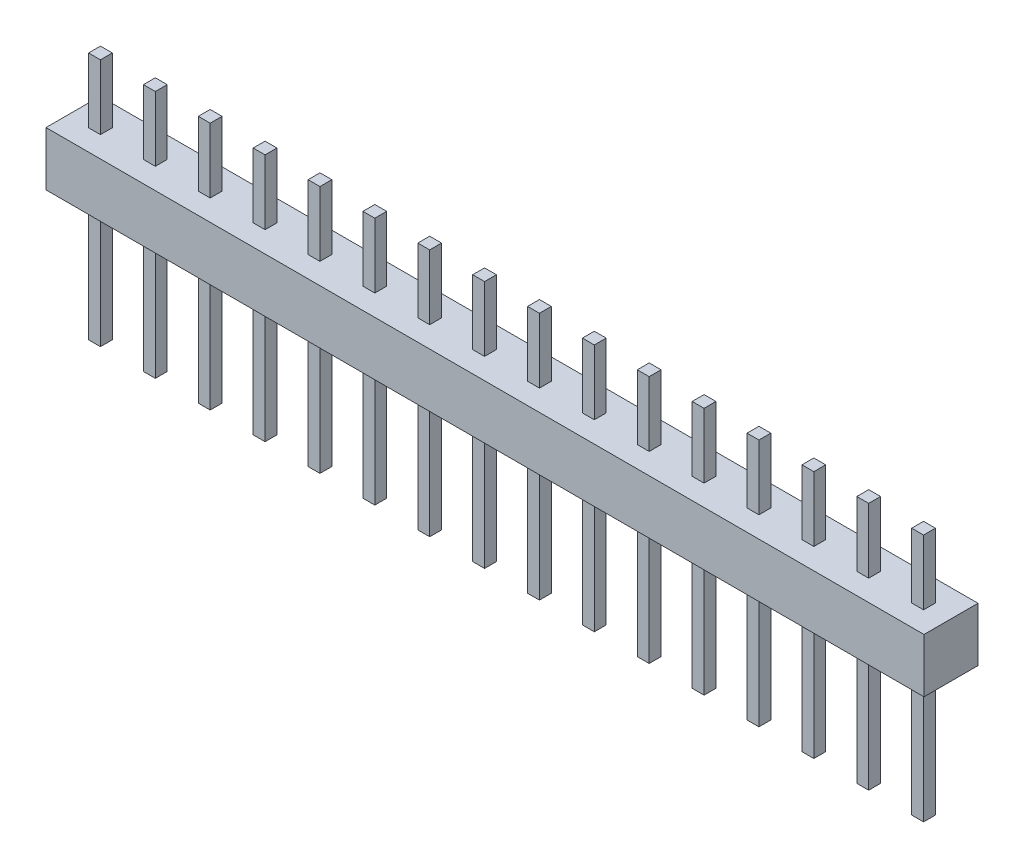
from build123d import *

# Parameters (mm, degrees)
SKETCH1_W              = 40.64
SKETCH1_H              = 2.5
BOSS_EXTRUDE1_DEPTH    = 1.25
SKETCH2_W              = 0.55
SKETCH2_H              = 0.55
BOSS_EXTRUDE2_DEPTH    = 6
BOSS_EXTRUDE2_2_DEPTH  = 6
BOSS_EXTRUDE2_3_DEPTH  = 6
BOSS_EXTRUDE2_4_DEPTH  = 6
BOSS_EXTRUDE2_5_DEPTH  = 6
BOSS_EXTRUDE2_6_DEPTH  = 6
BOSS_EXTRUDE2_7_DEPTH  = 6
BOSS_EXTRUDE2_8_DEPTH  = 6
BOSS_EXTRUDE2_9_DEPTH  = 6
BOSS_EXTRUDE2_10_DEPTH = 6
BOSS_EXTRUDE2_11_DEPTH = 6
BOSS_EXTRUDE2_12_DEPTH = 6
BOSS_EXTRUDE2_13_DEPTH = 6
BOSS_EXTRUDE2_14_DEPTH = 6
BOSS_EXTRUDE2_15_DEPTH = 6
BOSS_EXTRUDE2_16_DEPTH = 6
SKETCH2_2_W            = 0.55
SKETCH2_2_H            = 0.55
BOSS_EXTRUDE3_DEPTH    = 5.5
BOSS_EXTRUDE3_2_DEPTH  = 5.5
BOSS_EXTRUDE3_3_DEPTH  = 5.5
BOSS_EXTRUDE3_4_DEPTH  = 5.5
BOSS_EXTRUDE3_5_DEPTH  = 5.5
BOSS_EXTRUDE3_6_DEPTH  = 5.5
BOSS_EXTRUDE3_7_DEPTH  = 5.5
BOSS_EXTRUDE3_8_DEPTH  = 5.5
BOSS_EXTRUDE3_9_DEPTH  = 5.5
BOSS_EXTRUDE3_10_DEPTH = 5.5
BOSS_EXTRUDE3_11_DEPTH = 5.5
BOSS_EXTRUDE3_12_DEPTH = 5.5
BOSS_EXTRUDE3_13_DEPTH = 5.5
BOSS_EXTRUDE3_14_DEPTH = 5.5
BOSS_EXTRUDE3_15_DEPTH = 5.5
BOSS_EXTRUDE3_16_DEPTH = 5.5


with BuildPart() as part:
    # Sketch1 → Boss-Extrude1 (new body, symmetric)
    with BuildSketch(Plane.XY):
        with Locations((20.32, 1.25)):
            Rectangle(SKETCH1_W, SKETCH1_H)
    extrude(amount=BOSS_EXTRUDE1_DEPTH, both=True)


with BuildPart() as body_2:
    # Sketch2 → Boss-Extrude2 (new body)
    with BuildSketch(Plane.XZ):
        with Locations((3.81, 0)):
            Rectangle(SKETCH2_W, SKETCH2_H)
    extrude(amount=BOSS_EXTRUDE2_DEPTH)


with BuildPart() as body_3:
    # Sketch2 → Boss-Extrude2 2 (new body)
    with BuildSketch(Plane.XZ):
        with Locations((1.27, 0)):
            Rectangle(SKETCH2_W, SKETCH2_H)
    extrude(amount=BOSS_EXTRUDE2_2_DEPTH)


with BuildPart() as body_4:
    # Sketch2 → Boss-Extrude2 3 (new body)
    with BuildSketch(Plane.XZ):
        with Locations((6.35, 0)):
            Rectangle(SKETCH2_W, SKETCH2_H)
    extrude(amount=BOSS_EXTRUDE2_3_DEPTH)


with BuildPart() as body_5:
    # Sketch2 → Boss-Extrude2 4 (new body)
    with BuildSketch(Plane.XZ):
        with Locations((8.89, 0)):
            Rectangle(SKETCH2_W, SKETCH2_H)
    extrude(amount=BOSS_EXTRUDE2_4_DEPTH)


with BuildPart() as body_6:
    # Sketch2 → Boss-Extrude2 5 (new body)
    with BuildSketch(Plane.XZ):
        with Locations((11.43, 0)):
            Rectangle(SKETCH2_W, SKETCH2_H)
    extrude(amount=BOSS_EXTRUDE2_5_DEPTH)


with BuildPart() as body_7:
    # Sketch2 → Boss-Extrude2 6 (new body)
    with BuildSketch(Plane.XZ):
        with Locations((13.97, 0)):
            Rectangle(SKETCH2_W, SKETCH2_H)
    extrude(amount=BOSS_EXTRUDE2_6_DEPTH)


with BuildPart() as body_8:
    # Sketch2 → Boss-Extrude2 7 (new body)
    with BuildSketch(Plane.XZ):
        with Locations((16.51, 0)):
            Rectangle(SKETCH2_W, SKETCH2_H)
    extrude(amount=BOSS_EXTRUDE2_7_DEPTH)


with BuildPart() as body_9:
    # Sketch2 → Boss-Extrude2 8 (new body)
    with BuildSketch(Plane.XZ):
        with Locations((19.05, 0)):
            Rectangle(SKETCH2_W, SKETCH2_H)
    extrude(amount=BOSS_EXTRUDE2_8_DEPTH)


with BuildPart() as body_10:
    # Sketch2 → Boss-Extrude2 9 (new body)
    with BuildSketch(Plane.XZ):
        with Locations((21.59, 0)):
            Rectangle(SKETCH2_W, SKETCH2_H)
    extrude(amount=BOSS_EXTRUDE2_9_DEPTH)


with BuildPart() as body_11:
    # Sketch2 → Boss-Extrude2 10 (new body)
    with BuildSketch(Plane.XZ):
        with Locations((24.13, 0)):
            Rectangle(SKETCH2_W, SKETCH2_H)
    extrude(amount=BOSS_EXTRUDE2_10_DEPTH)


with BuildPart() as body_12:
    # Sketch2 → Boss-Extrude2 11 (new body)
    with BuildSketch(Plane.XZ):
        with Locations((26.67, 0)):
            Rectangle(SKETCH2_W, SKETCH2_H)
    extrude(amount=BOSS_EXTRUDE2_11_DEPTH)


with BuildPart() as body_13:
    # Sketch2 → Boss-Extrude2 12 (new body)
    with BuildSketch(Plane.XZ):
        with Locations((29.21, 0)):
            Rectangle(SKETCH2_W, SKETCH2_H)
    extrude(amount=BOSS_EXTRUDE2_12_DEPTH)


with BuildPart() as body_14:
    # Sketch2 → Boss-Extrude2 13 (new body)
    with BuildSketch(Plane.XZ):
        with Locations((31.75, 0)):
            Rectangle(SKETCH2_W, SKETCH2_H)
    extrude(amount=BOSS_EXTRUDE2_13_DEPTH)


with BuildPart() as body_15:
    # Sketch2 → Boss-Extrude2 14 (new body)
    with BuildSketch(Plane.XZ):
        with Locations((34.29, 0)):
            Rectangle(SKETCH2_W, SKETCH2_H)
    extrude(amount=BOSS_EXTRUDE2_14_DEPTH)


with BuildPart() as body_16:
    # Sketch2 → Boss-Extrude2 15 (new body)
    with BuildSketch(Plane.XZ):
        with Locations((36.83, 0)):
            Rectangle(SKETCH2_W, SKETCH2_H)
    extrude(amount=BOSS_EXTRUDE2_15_DEPTH)


with BuildPart() as body_17:
    # Sketch2 → Boss-Extrude2 16 (new body)
    with BuildSketch(Plane.XZ):
        with Locations((39.37, 0)):
            Rectangle(SKETCH2_W, SKETCH2_H)
    extrude(amount=BOSS_EXTRUDE2_16_DEPTH)


with BuildPart() as body_18:
    # Sketch2_2 → Boss-Extrude3 (new body)
    with BuildSketch(Plane.XZ):
        with Locations((3.81, 0)):
            Rectangle(SKETCH2_2_W, SKETCH2_2_H)
    extrude(amount=-BOSS_EXTRUDE3_DEPTH)


with BuildPart() as body_19:
    # Sketch2_2 → Boss-Extrude3 2 (new body)
    with BuildSketch(Plane.XZ):
        with Locations((1.27, 0)):
            Rectangle(SKETCH2_2_W, SKETCH2_2_H)
    extrude(amount=-BOSS_EXTRUDE3_2_DEPTH)


with BuildPart() as body_20:
    # Sketch2_2 → Boss-Extrude3 3 (new body)
    with BuildSketch(Plane.XZ):
        with Locations((6.35, 0)):
            Rectangle(SKETCH2_2_W, SKETCH2_2_H)
    extrude(amount=-BOSS_EXTRUDE3_3_DEPTH)


with BuildPart() as body_21:
    # Sketch2_2 → Boss-Extrude3 4 (new body)
    with BuildSketch(Plane.XZ):
        with Locations((8.89, 0)):
            Rectangle(SKETCH2_2_W, SKETCH2_2_H)
    extrude(amount=-BOSS_EXTRUDE3_4_DEPTH)


with BuildPart() as body_22:
    # Sketch2_2 → Boss-Extrude3 5 (new body)
    with BuildSketch(Plane.XZ):
        with Locations((11.43, 0)):
            Rectangle(SKETCH2_2_W, SKETCH2_2_H)
    extrude(amount=-BOSS_EXTRUDE3_5_DEPTH)


with BuildPart() as body_23:
    # Sketch2_2 → Boss-Extrude3 6 (new body)
    with BuildSketch(Plane.XZ):
        with Locations((13.97, 0)):
            Rectangle(SKETCH2_2_W, SKETCH2_2_H)
    extrude(amount=-BOSS_EXTRUDE3_6_DEPTH)


with BuildPart() as body_24:
    # Sketch2_2 → Boss-Extrude3 7 (new body)
    with BuildSketch(Plane.XZ):
        with Locations((16.51, 0)):
            Rectangle(SKETCH2_2_W, SKETCH2_2_H)
    extrude(amount=-BOSS_EXTRUDE3_7_DEPTH)


with BuildPart() as body_25:
    # Sketch2_2 → Boss-Extrude3 8 (new body)
    with BuildSketch(Plane.XZ):
        with Locations((19.05, 0)):
            Rectangle(SKETCH2_2_W, SKETCH2_2_H)
    extrude(amount=-BOSS_EXTRUDE3_8_DEPTH)


with BuildPart() as body_26:
    # Sketch2_2 → Boss-Extrude3 9 (new body)
    with BuildSketch(Plane.XZ):
        with Locations((21.59, 0)):
            Rectangle(SKETCH2_2_W, SKETCH2_2_H)
    extrude(amount=-BOSS_EXTRUDE3_9_DEPTH)


with BuildPart() as body_27:
    # Sketch2_2 → Boss-Extrude3 10 (new body)
    with BuildSketch(Plane.XZ):
        with Locations((24.13, 0)):
            Rectangle(SKETCH2_2_W, SKETCH2_2_H)
    extrude(amount=-BOSS_EXTRUDE3_10_DEPTH)


with BuildPart() as body_28:
    # Sketch2_2 → Boss-Extrude3 11 (new body)
    with BuildSketch(Plane.XZ):
        with Locations((26.67, 0)):
            Rectangle(SKETCH2_2_W, SKETCH2_2_H)
    extrude(amount=-BOSS_EXTRUDE3_11_DEPTH)


with BuildPart() as body_29:
    # Sketch2_2 → Boss-Extrude3 12 (new body)
    with BuildSketch(Plane.XZ):
        with Locations((29.21, 0)):
            Rectangle(SKETCH2_2_W, SKETCH2_2_H)
    extrude(amount=-BOSS_EXTRUDE3_12_DEPTH)


with BuildPart() as body_30:
    # Sketch2_2 → Boss-Extrude3 13 (new body)
    with BuildSketch(Plane.XZ):
        with Locations((31.75, 0)):
            Rectangle(SKETCH2_2_W, SKETCH2_2_H)
    extrude(amount=-BOSS_EXTRUDE3_13_DEPTH)


with BuildPart() as body_31:
    # Sketch2_2 → Boss-Extrude3 14 (new body)
    with BuildSketch(Plane.XZ):
        with Locations((34.29, 0)):
            Rectangle(SKETCH2_2_W, SKETCH2_2_H)
    extrude(amount=-BOSS_EXTRUDE3_14_DEPTH)


with BuildPart() as body_32:
    # Sketch2_2 → Boss-Extrude3 15 (new body)
    with BuildSketch(Plane.XZ):
        with Locations((36.83, 0)):
            Rectangle(SKETCH2_2_W, SKETCH2_2_H)
    extrude(amount=-BOSS_EXTRUDE3_15_DEPTH)


with BuildPart() as body_33:
    # Sketch2_2 → Boss-Extrude3 16 (new body)
    with BuildSketch(Plane.XZ):
        with Locations((39.37, 0)):
            Rectangle(SKETCH2_2_W, SKETCH2_2_H)
    extrude(amount=-BOSS_EXTRUDE3_16_DEPTH)


solid = Compound([part.part, body_2.part, body_3.part, body_4.part, body_5.part, body_6.part, body_7.part, body_8.part, body_9.part, body_10.part, body_11.part, body_12.part, body_13.part, body_14.part, body_15.part, body_16.part, body_17.part, body_18.part, body_19.part, body_20.part, body_21.part, body_22.part, body_23.part, body_24.part, body_25.part, body_26.part, body_27.part, body_28.part, body_29.part, body_30.part, body_31.part, body_32.part, body_33.part])
